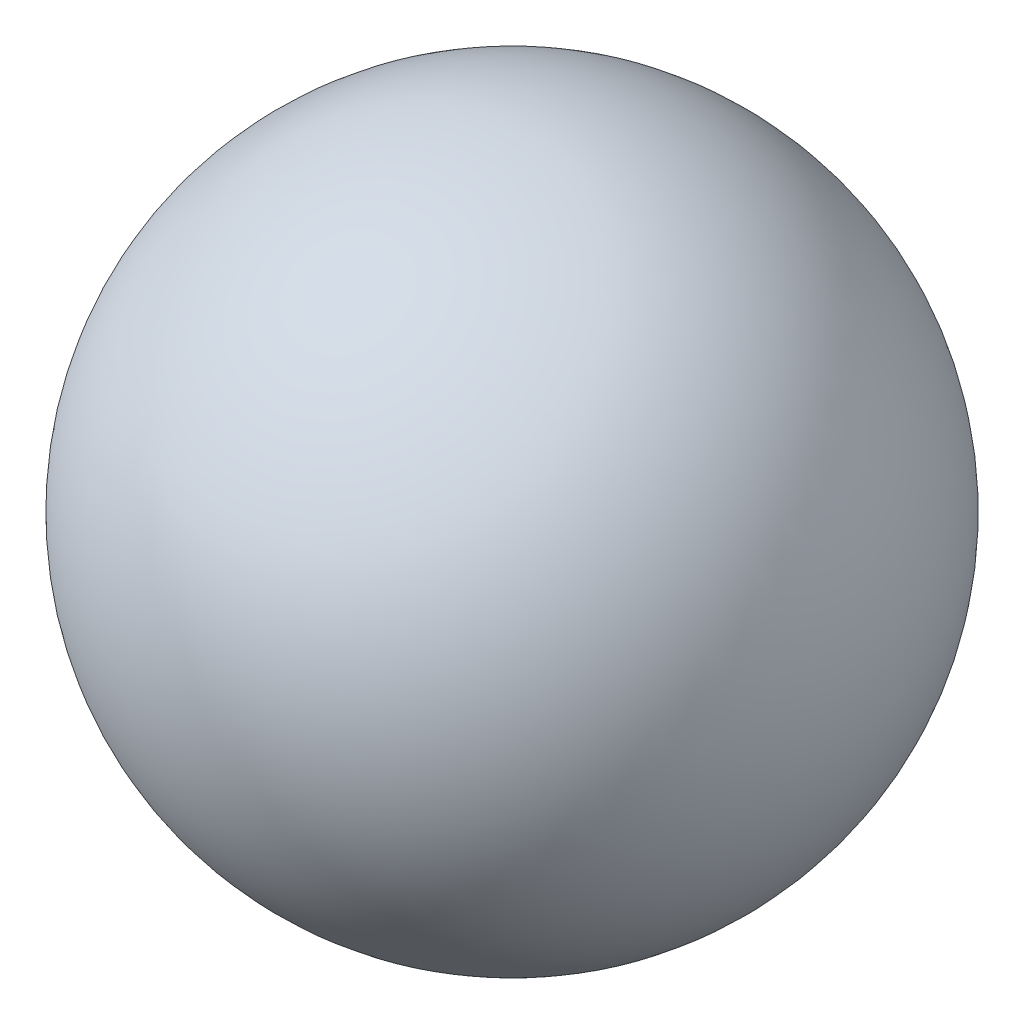
from build123d import *


with BuildPart() as part:
    # Esquisse1 → Révolution2 (revolve)
    with BuildSketch(Plane.XY):
        with BuildLine():
            Line((0, 2.5), (0, -2.5))
            ThreePointArc((0, -2.5), (-2.5, 0), (0, 2.5))
        make_face()
    revolve(axis=Axis((0, 2.5, 0), (0, -1, 0)))


solid = part.part
